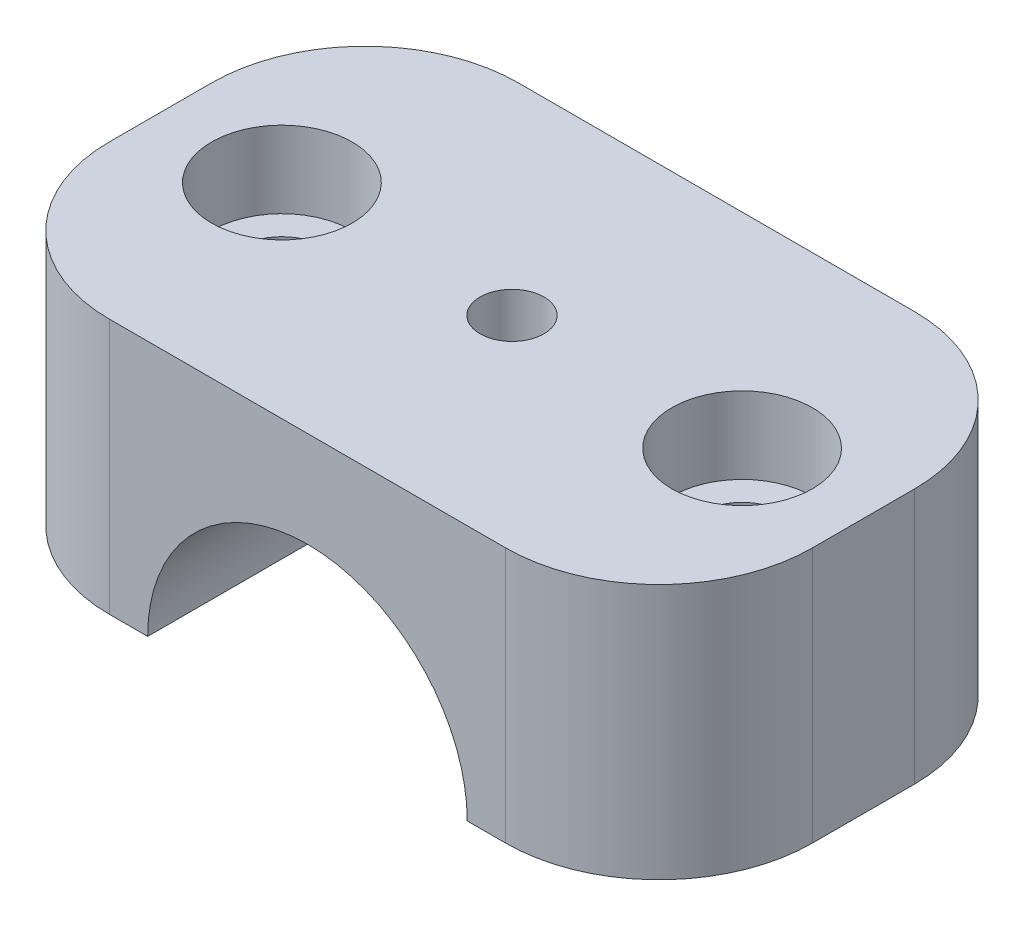
from build123d import *

# Parameters (mm, degrees)
SKETCH1_W                      = 55
SKETCH1_H                      = 20
BOSS_EXTRUDE1_DEPTH            = 32
SKETCH2_R                      = 12.5
CUT_EXTRUDE1_DEPTH             = 33
FILLET1_R                      = 12
CBORE_FOR_M6_SHCS4_D           = 6.6
CBORE_FOR_M6_SHCS4_CBORE_D     = 11
CBORE_FOR_M6_SHCS4_CBORE_DEPTH = 6
SKETCH18_R                     = 2.5
CUT_EXTRUDE2_DEPTH             = 21


with BuildPart() as part:
    # Sketch1 → Boss-Extrude1 (new body)
    with BuildSketch(Plane.XY):
        with Locations((0, 10)):
            Rectangle(SKETCH1_W, SKETCH1_H)
    extrude(amount=BOSS_EXTRUDE1_DEPTH)

    # Sketch2 → Cut-Extrude1 (cut, through all)
    with BuildSketch(Plane.XY.offset(32)):
        Circle(SKETCH2_R)
    extrude(amount=-CUT_EXTRUDE1_DEPTH, mode=Mode.SUBTRACT)

    # Fillet1
    fillet1_edges = [part.edges().sort_by_distance(p)[0] for p in [
        (27.5, 10, 32),
        (-27.5, 10, 32),
        (27.5, 10, 0),
        (-27.5, 10, 0),
    ]]
    fillet(fillet1_edges, radius=FILLET1_R)

    # CBORE for M6 SHCS4 (through all)
    with Locations(Plane(origin=(0, 20, 0), x_dir=(1, 0, 0), z_dir=(0, 1, 0))):
        with Locations((18, -16)):
            cbore_for_m6_shcs4 = CounterBoreHole(CBORE_FOR_M6_SHCS4_D / 2, CBORE_FOR_M6_SHCS4_CBORE_D / 2, CBORE_FOR_M6_SHCS4_CBORE_DEPTH)

    # Mirror2: CBORE for M6 SHCS4 across plane
    add(cbore_for_m6_shcs4.mirror(Plane(origin=(0, 0, 0), x_dir=(0, 0, 1), z_dir=(1, 0, 0))), mode=Mode.SUBTRACT)

    # Sketch18 → Cut-Extrude2 (cut, through all)
    with BuildSketch(Plane(origin=(0, 20, 0), x_dir=(1, 0, 0), z_dir=(0, 1, 0))):
        with Locations(Location((0, -16, 0), (0, 0, 270))):  # turned: the seam where the file's is
            Circle(SKETCH18_R)
    extrude(amount=-CUT_EXTRUDE2_DEPTH, mode=Mode.SUBTRACT)


solid = part.part
